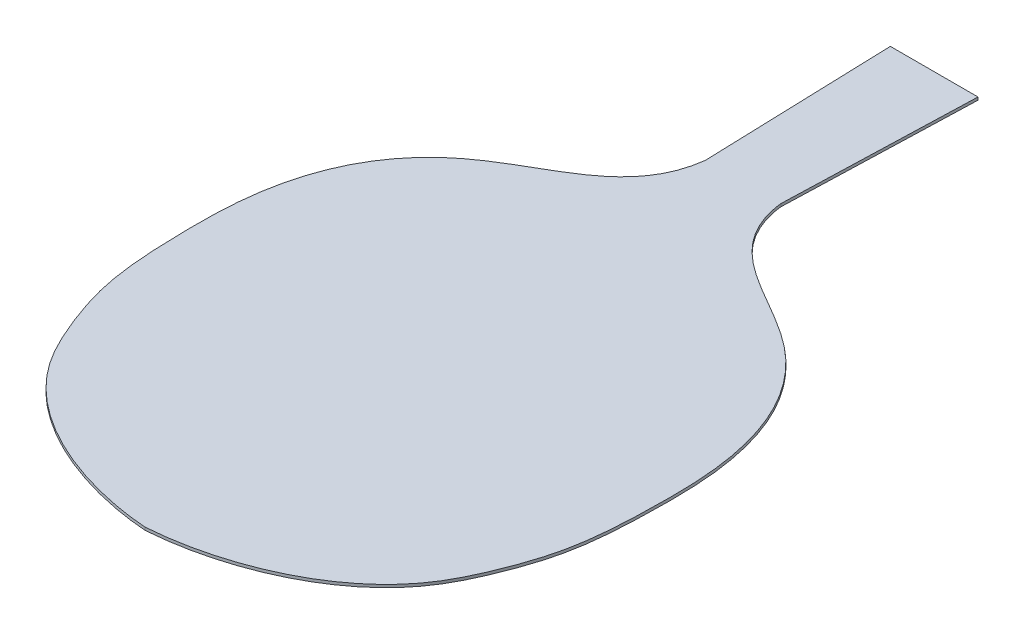
from build123d import *

# Parameters (mm, degrees)
BOSS_EXTRUDE1_DEPTH = 0.9


with BuildPart() as part:
    # Sketch1 → Boss-Extrude1 (new body)
    with BuildSketch(Plane(origin=(0, 0, 0), x_dir=(1, 0, 0), z_dir=(0, 1, 0))):
        with BuildLine():
            Line((-14, 126), (14, 126))
            Line((14, 126), (12.010869565, 65))
            add(Edge.make_bspline(
                [(0, -126), (21.433619385, -124.481891069), (53.814336013, -112.472945485), (68.353116066, -81.439281394), (74.54638909, -63.145782756), (75.743897619, -41.002981951), (75.640582841, -15.527359986), (68.952122949, 7.612822047), (55.542429665, 24.475938434), (32.950199531, 38.640758932), (14.028578126, 47.884779804), (12.010869565, 65)],
                knots=[0, 0, 0, 0, 0.267560962, 0.332938778, 0.394006326, 0.491426816, 0.588441347, 0.690220593, 0.76470456, 0.833002171, 1, 1, 1, 1], degree=3))
            add(Edge.make_bspline(
                [(0, -126), (-21.433619385, -124.481891069), (-53.814336013, -112.472945485), (-68.353116066, -81.439281394), (-74.54638909, -63.145782756), (-75.743897619, -41.002981951), (-75.640582841, -15.527359986), (-68.952122949, 7.612822047), (-55.542429665, 24.475938434), (-32.950199531, 38.640758932), (-14.028578126, 47.884779804), (-12.010869565, 65)],
                knots=[0, 0, 0, 0, 0.267560962, 0.332938778, 0.394006326, 0.491426816, 0.588441347, 0.690220593, 0.76470456, 0.833002171, 1, 1, 1, 1], degree=3))
            Line((-12.010869565, 65), (-14, 126))
        make_face()
    extrude(amount=BOSS_EXTRUDE1_DEPTH)


solid = part.part
